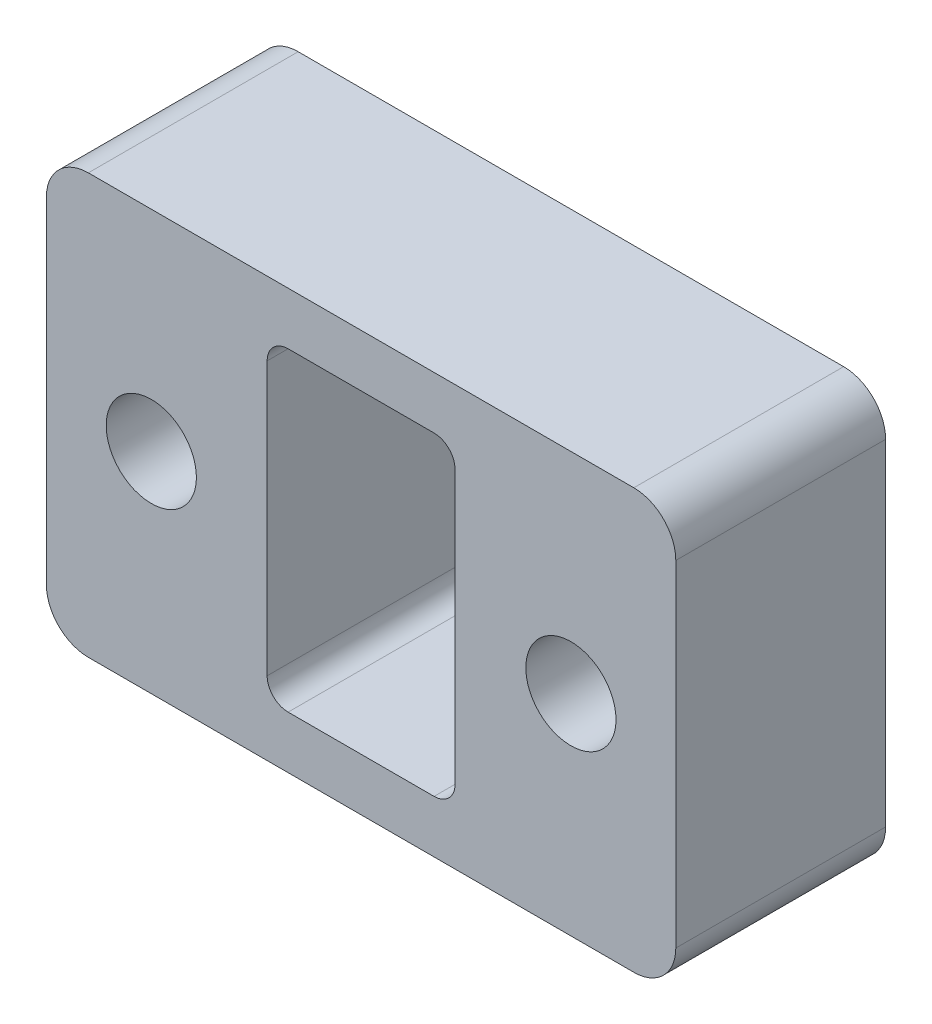
from build123d import *

# Parameters (mm, degrees)
SKETCH_1_W      = 30
SKETCH_1_H      = 20
SKETCH_1_R      = 2.15
SKETCH_1_W_2    = 8.956326716
SKETCH_1_H_2    = 15
EXTRUDE_1_DEPTH = 10
FILLET_1_R      = 1
FILLET_2_R      = 2


with BuildPart() as part:
    # 草图1 → 凸台-拉伸1 (new body)
    with BuildSketch(Plane.XY):
        Rectangle(SKETCH_1_W, SKETCH_1_H)
        with Locations((-10, 0)):
            Circle(SKETCH_1_R, mode=Mode.SUBTRACT)
        with Locations((10, 0)):
            Circle(SKETCH_1_R, mode=Mode.SUBTRACT)
        Rectangle(SKETCH_1_W_2, SKETCH_1_H_2, mode=Mode.SUBTRACT)
    extrude(amount=EXTRUDE_1_DEPTH)

    # 圆角1
    fillet_1_edges = [part.edges().sort_by_distance(p)[0] for p in [
        (4.478163358, -7.5, 5),
        (4.478163358, 7.5, 5),
        (-4.478163358, 7.5, 5),
        (-4.478163358, -7.5, 5),
    ]]
    fillet(fillet_1_edges, radius=FILLET_1_R)

    # 圆角2
    fillet_2_edges = [part.edges().sort_by_distance(p)[0] for p in [
        (15, -10, 5),
        (-15, -10, 5),
        (-15, 10, 5),
        (15, 10, 5),
    ]]
    fillet(fillet_2_edges, radius=FILLET_2_R)


solid = part.part
